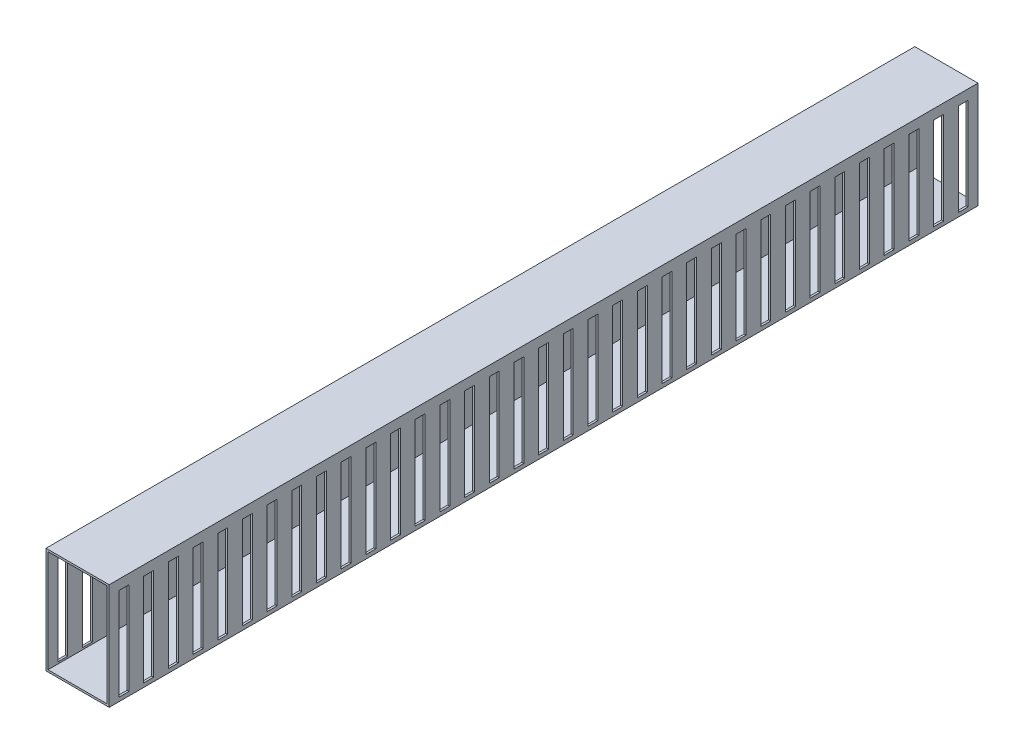
from build123d import *

# Parameters (mm, degrees)
ESQUISSE1_W                = 32
ESQUISSE1_H                = 53.8
ESQUISSE1_W_2              = 30
ESQUISSE1_H_2              = 51.8
BOSS_EXTRU_1_DEPTH         = 440
ESQUISSE2_W                = 5
ESQUISSE2_H                = 46.8
ENL_V_MAT_EXTRU_1_DEPTH    = 32
R_P_TITION_LIN_AIRE1_COUNT = 35
R_P_TITION_LIN_AIRE1_PITCH = 12.5


with BuildPart() as part:
    # Esquisse1 → Boss.-Extru.1 (new body)
    with BuildSketch(Plane.XY):
        with Locations((2.977116986, 10.236099585)):
            Rectangle(ESQUISSE1_W, ESQUISSE1_H)
        with Locations((2.977116986, 10.236099585)):
            Rectangle(ESQUISSE1_W_2, ESQUISSE1_H_2, mode=Mode.SUBTRACT)
    extrude(amount=BOSS_EXTRU_1_DEPTH)

    # Esquisse2 → Enlèv. mat.-Extru.1 (cut)
    with BuildSketch(Plane(origin=(18.977116986, 0, 0), x_dir=(0, 0, -1), z_dir=(1, 0, 0))):
        with Locations((-7.5, 8.736099585)):
            Rectangle(ESQUISSE2_W, ESQUISSE2_H)
    enl_v_mat_extru_1 = extrude(amount=-ENL_V_MAT_EXTRU_1_DEPTH, mode=Mode.SUBTRACT)

    # Répétition linéaire1: Enlèv. mat.-Extru.1 ×35
    with Locations(*[(0, 0, i * R_P_TITION_LIN_AIRE1_PITCH) for i in range(1, R_P_TITION_LIN_AIRE1_COUNT)]):
        add(enl_v_mat_extru_1, mode=Mode.SUBTRACT)


solid = part.part
